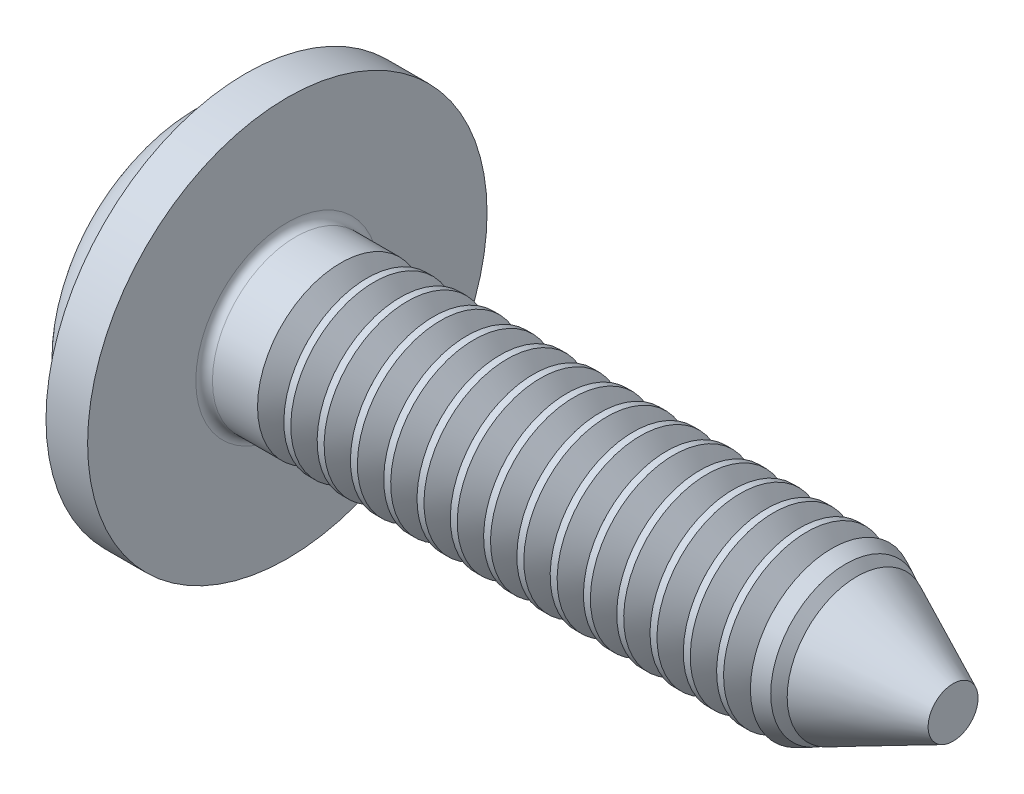
from build123d import *

# Parameters (mm, degrees)
FILLET1_R                = 0.1
SKETCH3_W                = 0.48
SKETCH3_H                = 2.1
SKETCH4_W                = 0.48
SKETCH4_H                = 0.68402847
RECPAT_COUNT             = 2
RECPAT_ANGLE             = 90
THDSCHPAT_COUNT          = 19
THDSCHPAT_PITCH          = 0.4
ESBO_O1_R                = 2.4
RESSALTO_EXTRUS_O1_DEPTH = 0.5


with BuildPart() as part:
    # BodySke → Base-Revolve (revolve)
    with BuildSketch(Plane.XY):
        with BuildLine():
            Line((1.6, 1), (1.6, 2))
            Line((1.6, 2), (1.1, 2))
            ThreePointArc((1.1, 2), (0.688403396, 1.885994341), (0.394117647, 1.576470588))
            ThreePointArc((0.394117647, 1.576470588), (0.100022625, 0.812494344), (0, 0))
            Line((0, 0), (9.6, 0))
            Line((9.6, 0), (9.6, 1))
            Line((9.6, 1), (1.6, 1))
        make_face()
    revolve(axis=Axis((-25.4, 0, 0), (1, 0, 0)))

    # Fillet1
    fillet1_edges = [part.edges().sort_by_distance(p)[0] for p in [
        (1.6, -1, 0),
    ]]
    fillet(fillet1_edges, radius=FILLET1_R)

    # Sketch3 → Recess section 0
    with BuildSketch(Plane(origin=(0, 0, 0), x_dir=(0, 0, -1), z_dir=(1, 0, 0))):
        Rectangle(SKETCH3_W, SKETCH3_H)
    # Sketch4 → Recess section 1
    with BuildSketch(Plane(origin=(1.42, 0, 0), x_dir=(0, 0, -1), z_dir=(1, 0, 0))):
        Rectangle(SKETCH4_W, SKETCH4_H)
    recess = loft(mode=Mode.SUBTRACT)

    # RecPat: Recess ×2 about axis
    recpat_axis = Axis((0, 0, 0), (1, 0, 0))
    for i in range(1, RECPAT_COUNT):
        add(recess.rotate(recpat_axis, i * RECPAT_ANGLE / (RECPAT_COUNT - 1)), mode=Mode.SUBTRACT)

    # RecCorSke → RecessCore (revolve, cut)
    with BuildSketch(Plane.XY):
        Polygon((0, 0), (0, 0.454796073), (1.42, 0.3555), (1.535508952, 0), align=None)
    revolve(axis=Axis((-3.175, 0, 0), (1, 0, 0)), mode=Mode.SUBTRACT)

    # ThdSchSke → ThreadSchematic (revolve, cut)
    with BuildSketch(Plane.XY):
        Polygon((2.4, -0.774), (2.241753096, -1), (2.241753096, -1.25), (2.558246904, -1.25), (2.558246904, -1), align=None)
    threadschematic = revolve(axis=Axis((-3.175, 0, 0), (1, 0, 0)), mode=Mode.SUBTRACT)

    # ThdSchPat: ThreadSchematic ×19
    with Locations(*[(i * THDSCHPAT_PITCH, 0, 0) for i in range(1, THDSCHPAT_COUNT)]):
        add(threadschematic, mode=Mode.SUBTRACT)

    # Esboço1 → Ressalto-extrusão1 (add)
    with BuildSketch(Plane(origin=(1.6, 0, 0), x_dir=(0, 0, -1), z_dir=(1, 0, 0))):
        Circle(ESBO_O1_R)
    extrude(amount=-RESSALTO_EXTRUS_O1_DEPTH)

    # Esboço2 → Corte-Revolução1 (revolve, cut)
    with BuildSketch(Plane(origin=(0, 0, 0), x_dir=(1, 0, 0), z_dir=(0, 1, 0))):
        Polygon((9.6, 0.3), (8.1, 1), (9.6, 1), align=None)
    revolve(axis=Axis((0, 0, 0), (1, 0, 0)), mode=Mode.SUBTRACT)


solid = part.part
